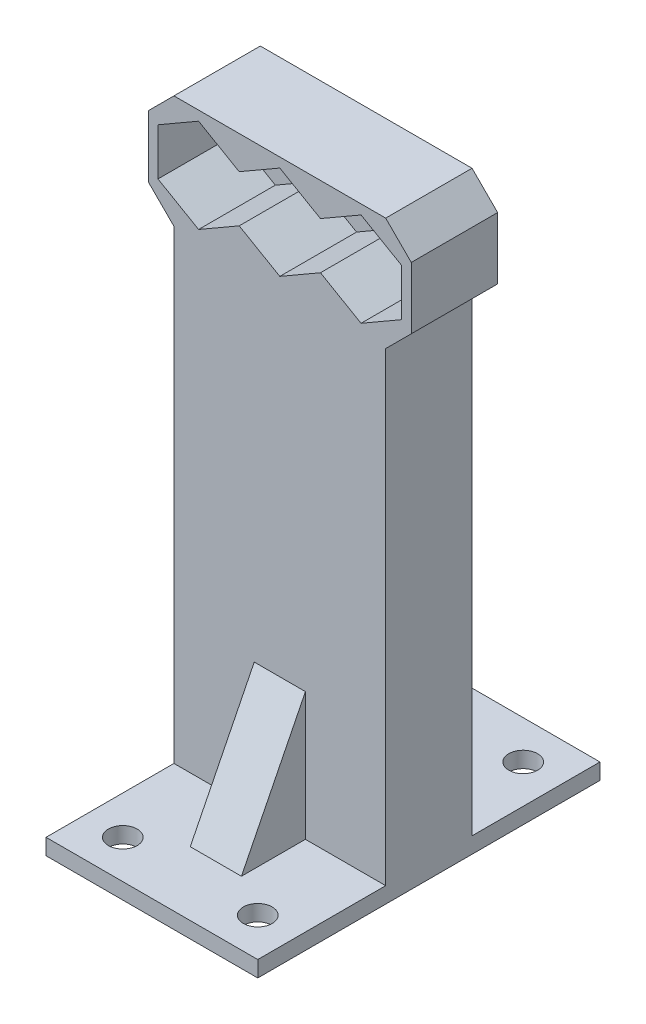
from build123d import *

# Parameters (mm, degrees)
SKETCH1_W           = 41.1
SKETCH1_H           = 17.664696838
BOSS_EXTRUDE1_DEPTH = 12
SKETCH2_W           = 41.1
SKETCH2_H           = 17.664696838
SKETCH2_R           = 4.75
BOSS_EXTRUDE2_DEPTH = 1.5
CHAMFER2_SIZE       = 4
SKETCH3_W           = 33.1
SKETCH3_H           = 13.5
BOSS_EXTRUDE3_DEPTH = 75.2176516
SKETCH4_W           = 33.1
SKETCH4_H           = 20
BOSS_EXTRUDE4_DEPTH = 2.5
CUT_EXTRUDE1_REACH  = 100.057
SKETCH5_R           = 2.25
RIB1_REACH          = 94.253
SKETCH6_WALL_W      = 208.867644448
SKETCH6_WALL_H      = 8
RIB2_REACH          = 94.253
SKETCH7_WALL_W      = 208.867644448
SKETCH7_WALL_H      = 8


with BuildPart() as part:
    # Sketch1 → Boss-Extrude1 (new body)
    with BuildSketch(Plane.XY):
        Rectangle(SKETCH1_W, SKETCH1_H)
        Polygon((-12.7, -7.332348419), (-6.35, -3.666174209), (0, -7.332348419), (6.35, -3.666174209), (12.7, -7.332348419), (19.05, -3.666174209), (19.05, 3.666174209), (12.7, 7.332348419), (6.35, 3.666174209), (0, 7.332348419), (-6.35, 3.666174209), (-12.7, 7.332348419), (-19.05, 3.666174209), (-19.05, -3.666174209), align=None, mode=Mode.SUBTRACT)
    extrude(amount=BOSS_EXTRUDE1_DEPTH)

    # Sketch2 → Boss-Extrude2 (add)
    with BuildSketch(Plane(origin=(0, 0, 0), x_dir=(-1, 0, 0), z_dir=(0, 0, -1))):
        Rectangle(SKETCH2_W, SKETCH2_H)
        Polygon((19.05, -3.666174209), (12.7, -7.332348419), (6.35, -3.666174209), (0, -7.332348419), (-6.35, -3.666174209), (-12.7, -7.332348419), (-19.05, -3.666174209), (-19.05, 3.666174209), (-12.7, 7.332348419), (-6.35, 3.666174209), (0, 7.332348419), (6.35, 3.666174209), (12.7, 7.332348419), (19.05, 3.666174209), align=None, mode=Mode.SUBTRACT)
        Polygon((6.35, -3.666174209), (6.35, 3.666174209), (12.7, 7.332348419), (19.05, 3.666174209), (19.05, -3.666174209), (12.7, -7.332348419), align=None)
        with Locations((12.7, 0)):
            Circle(SKETCH2_R, mode=Mode.SUBTRACT)
        Polygon((6.35, -3.666174209), (6.35, 3.666174209), (0, 7.332348419), (-6.35, 3.666174209), (-6.35, -3.666174209), (0, -7.332348419), align=None)
        Circle(SKETCH2_R, mode=Mode.SUBTRACT)
        Polygon((-6.35, 3.666174209), (-6.35, -3.666174209), (-12.7, -7.332348419), (-19.05, -3.666174209), (-19.05, 3.666174209), (-12.7, 7.332348419), align=None)
        with Locations((-12.7, 0)):
            Circle(SKETCH2_R, mode=Mode.SUBTRACT)
    extrude(amount=BOSS_EXTRUDE2_DEPTH)

    # Chamfer2
    chamfer2_edges = [part.edges().sort_by_distance(p)[0] for p in [
        (-20.55, -8.832348419, 5.25),
        (-20.55, 8.832348419, 5.25),
        (20.55, 8.832348419, 5.25),
        (20.55, -8.832348419, 5.25),
    ]]
    chamfer(chamfer2_edges, length=CHAMFER2_SIZE)

    # Sketch3 → Boss-Extrude3 (add)
    with BuildSketch(Plane.XZ.offset(8.832348419)):
        with Locations((0, 5.25)):
            Rectangle(SKETCH3_W, SKETCH3_H)
    extrude(amount=BOSS_EXTRUDE3_DEPTH)

    # Sketch4 → Boss-Extrude4 (add)
    with BuildSketch(Plane.XZ.offset(84.050000019)):
        with Locations((0, 22)):
            Rectangle(SKETCH4_W, SKETCH4_H)
        with Locations((0, -11.5)):
            Rectangle(SKETCH4_W, SKETCH4_H)
    extrude(amount=-BOSS_EXTRUDE4_DEPTH)

    # Sketch5 → Cut-Extrude1 (cut, up to next)
    with BuildSketch(Plane(origin=(0, -81.550000019, 0), x_dir=(1, 0, 0), z_dir=(0, 1, 0)), mode=Mode.PRIVATE) as cut_extrude1_sk1:
        with Locations(Location((-10.55, -26, 0), (0, 0, 270))):
            Circle(SKETCH5_R)
    cut_extrude1_tool1 = extrude(cut_extrude1_sk1.sketch, amount=-CUT_EXTRUDE1_REACH, mode=Mode.PRIVATE) & part.part
    # Sketch5 → Cut-Extrude1 (cut, up to next)
    with BuildSketch(Plane(origin=(0, -81.550000019, 0), x_dir=(1, 0, 0), z_dir=(0, 1, 0)), mode=Mode.PRIVATE) as cut_extrude1_sk2:
        with Locations(Location((10.55, -26, 0), (0, 0, 270))):
            Circle(SKETCH5_R)
    cut_extrude1_tool2 = extrude(cut_extrude1_sk2.sketch, amount=-CUT_EXTRUDE1_REACH, mode=Mode.PRIVATE) & part.part
    # Sketch5 → Cut-Extrude1 (cut, up to next)
    with BuildSketch(Plane(origin=(0, -81.550000019, 0), x_dir=(1, 0, 0), z_dir=(0, 1, 0)), mode=Mode.PRIVATE) as cut_extrude1_sk3:
        with Locations(Location((10.55, 15.5, 0), (0, 0, 270))):
            Circle(SKETCH5_R)
    cut_extrude1_tool3 = extrude(cut_extrude1_sk3.sketch, amount=-CUT_EXTRUDE1_REACH, mode=Mode.PRIVATE) & part.part
    # Sketch5 → Cut-Extrude1 (cut, up to next)
    with BuildSketch(Plane(origin=(0, -81.550000019, 0), x_dir=(1, 0, 0), z_dir=(0, 1, 0)), mode=Mode.PRIVATE) as cut_extrude1_sk4:
        with Locations(Location((-10.55, 15.5, 0), (0, 0, 270))):
            Circle(SKETCH5_R)
    cut_extrude1_tool4 = extrude(cut_extrude1_sk4.sketch, amount=-CUT_EXTRUDE1_REACH, mode=Mode.PRIVATE) & part.part
    add(cut_extrude1_tool1.solids().sort_by_distance((-10.55, -81.55, 26))[0], mode=Mode.SUBTRACT)
    add(cut_extrude1_tool2.solids().sort_by_distance((10.55, -81.55, 26))[0], mode=Mode.SUBTRACT)
    add(cut_extrude1_tool3.solids().sort_by_distance((10.55, -81.55, -15.5))[0], mode=Mode.SUBTRACT)
    add(cut_extrude1_tool4.solids().sort_by_distance((-10.55, -81.55, -15.5))[0], mode=Mode.SUBTRACT)

    # Sketch6 wall → Rib1 (add, up to next)
    with BuildSketch(Plane(origin=(0, -71.550000019, 17), x_dir=(0, 0.894427191, -0.4472135955), z_dir=(0, 0.4472135955, 0.894427191)), mode=Mode.PRIVATE) as rib1_sk1:
        Rectangle(SKETCH6_WALL_W, SKETCH6_WALL_H)
    rib1_tool1 = extrude(rib1_sk1.sketch, amount=-RIB1_REACH, mode=Mode.PRIVATE) - part.part
    add(rib1_tool1.solids().sort_by_distance((0, -71.550000019, 17))[0])

    # Sketch7 wall → Rib2 (add, up to next)
    with BuildSketch(Plane(origin=(0, -71.550000019, -6.5), x_dir=(0, -0.894427191, -0.4472135955), z_dir=(0, 0.4472135955, -0.894427191)), mode=Mode.PRIVATE) as rib2_sk1:
        Rectangle(SKETCH7_WALL_W, SKETCH7_WALL_H)
    rib2_tool1 = extrude(rib2_sk1.sketch, amount=-RIB2_REACH, mode=Mode.PRIVATE) - part.part
    add(rib2_tool1.solids().sort_by_distance((0, -71.550000019, -6.5))[0])


solid = part.part
